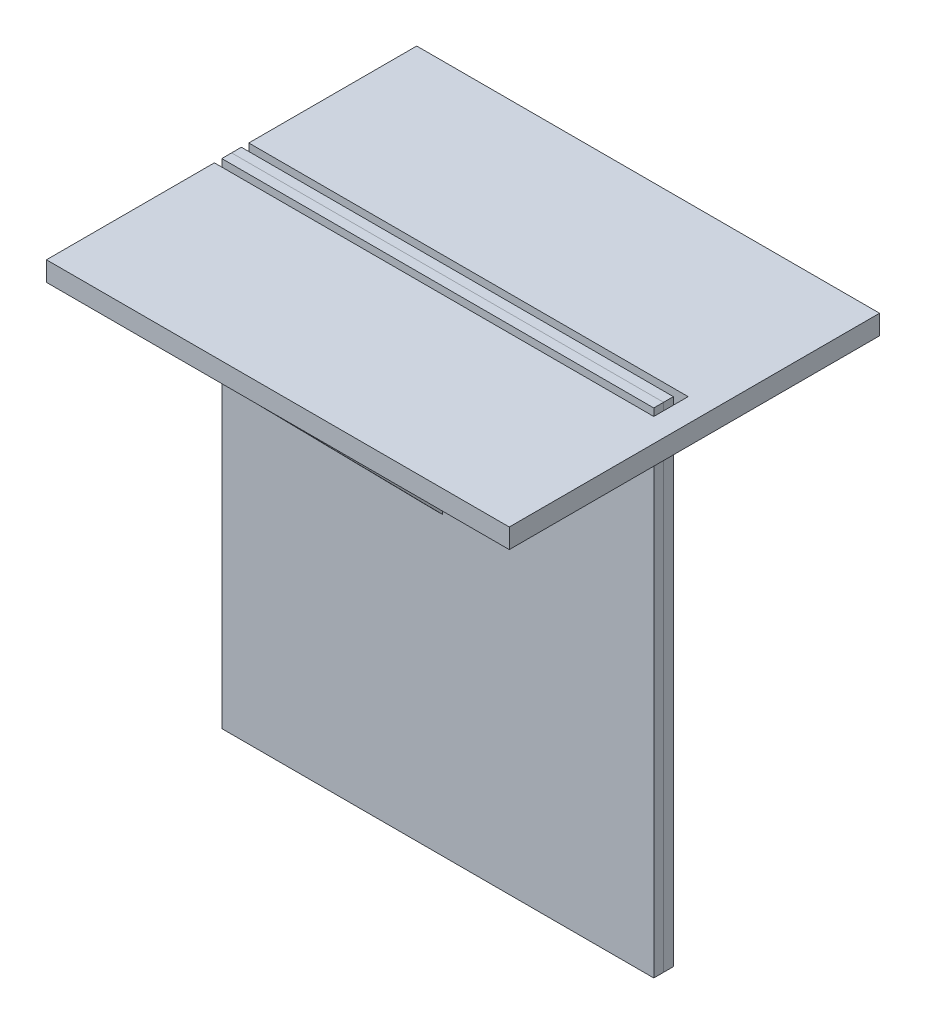
from build123d import *

# Parameters (mm, degrees)
SKETCH1_W           = 70
SKETCH1_H           = 80
BOSS_EXTRUDE1_DEPTH = 1.5875
SKETCH2_W           = 70
SKETCH2_H           = 80
SKETCH2_R           = 18.25
BOSS_EXTRUDE2_DEPTH = 1.5875
BOSS_EXTRUDE3_DEPTH = 3.175
BOSS_EXTRUDE4_DEPTH = 0.79375


with BuildPart() as part:
    # Sketch1 → Boss-Extrude1 (new body)
    with BuildSketch(Plane.XY):
        with Locations((0, 9)):
            Rectangle(SKETCH1_W, SKETCH1_H)
    extrude(amount=BOSS_EXTRUDE1_DEPTH)


with BuildPart() as body_2:
    # Sketch2 → Boss-Extrude2 (new body)
    with BuildSketch(Plane(origin=(0, 0, 0), x_dir=(-1, 0, 0), z_dir=(0, 0, -1))):
        with Locations((0, 9)):
            Rectangle(SKETCH2_W, SKETCH2_H)
        Circle(SKETCH2_R, mode=Mode.SUBTRACT)
    extrude(amount=BOSS_EXTRUDE2_DEPTH)


with BuildPart() as body_3:
    # Sketch3 → Boss-Extrude3 (new body)
    with BuildSketch(Plane.XZ.offset(-49)):
        Polygon((-35, 30), (40, 30), (40, -30), (-35, -30), (-35, -2.7875), (36.2, -2.7875), (36.2, 0), (36.2, 2.7875), (-35, 2.7875), align=None)
    extrude(amount=BOSS_EXTRUDE3_DEPTH)


with BuildPart() as body_4:
    # Sketch5 → Boss-Extrude4 (new body, symmetric)
    with BuildSketch(Plane.ZY):
        Polygon((30, 45.825), (1.5875, 16.934174077), (1.5875, 45.825), align=None)
    extrude(amount=BOSS_EXTRUDE4_DEPTH, both=True)


solid = Compound([part.part, body_2.part, body_3.part, body_4.part])
